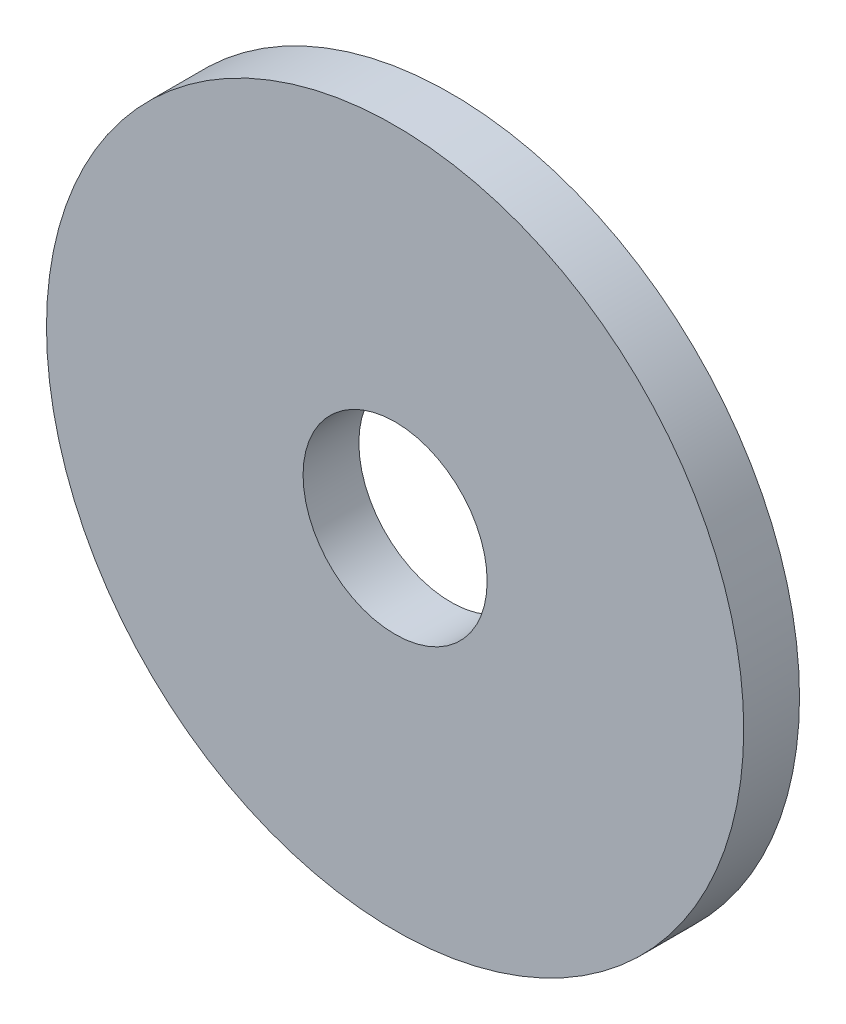
from build123d import *

# Parameters (mm, degrees)
ESQUISSE1_R          = 12.5
BOSS_EXTRU_1_DEPTH   = 2
D_GAGEMENT_M61_D     = 6.6
D_GAGEMENT_M61_DEPTH = 16
D_GAGEMENT_M61_TIP   = 1.982840043


with BuildPart() as part:
    # Esquisse1 → Boss.-Extru.1 (new body)
    with BuildSketch(Plane.XY):
        Circle(ESQUISSE1_R)
    extrude(amount=BOSS_EXTRU_1_DEPTH)

    # Dégagement M61
    with Locations(Plane(origin=(0, 0, 0), x_dir=(-1, 0, 0), z_dir=(0, 0, -1))):
        with Locations((0, 0)):
            Hole(D_GAGEMENT_M61_D / 2, depth=D_GAGEMENT_M61_DEPTH)
            with Locations((0, 0, -(D_GAGEMENT_M61_DEPTH + D_GAGEMENT_M61_TIP / 2))):  # 118° drill point
                Cone(0, D_GAGEMENT_M61_D / 2, D_GAGEMENT_M61_TIP, mode=Mode.SUBTRACT)


solid = part.part
